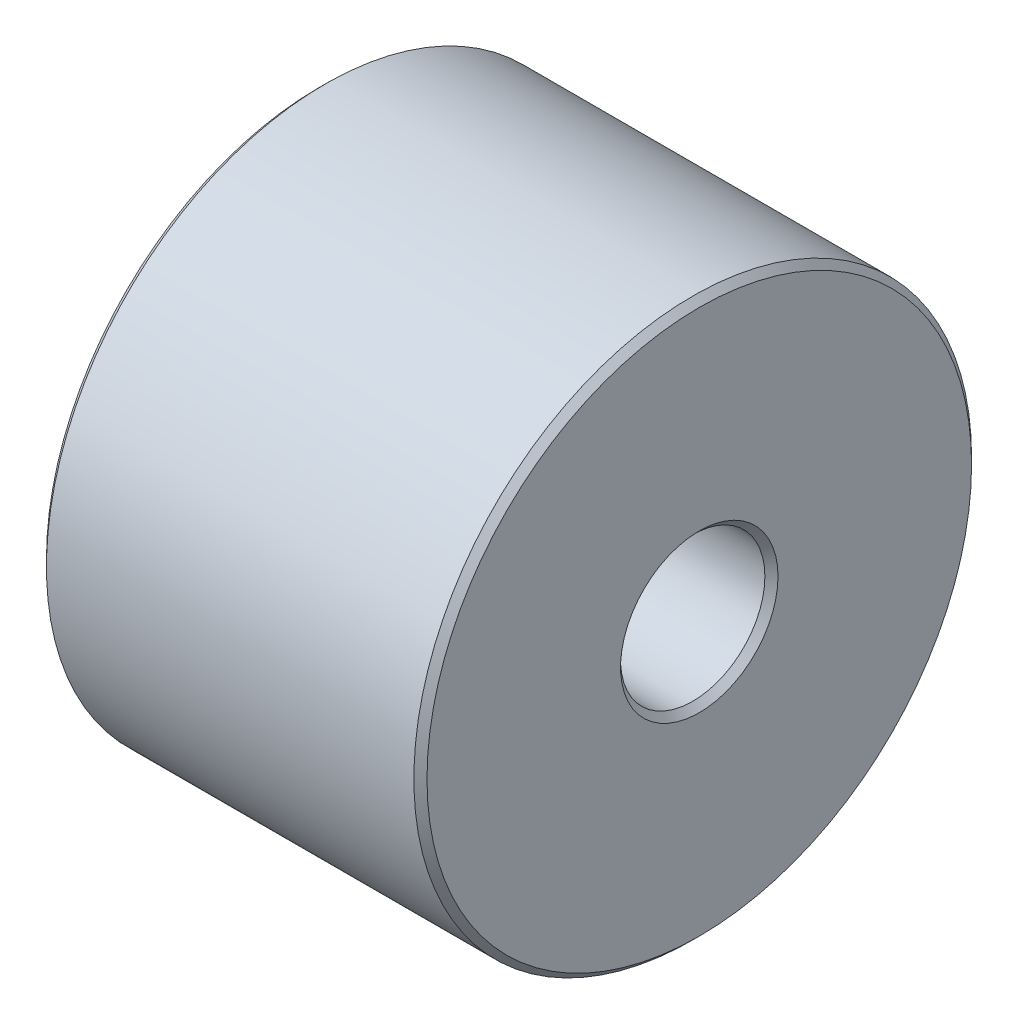
from build123d import *

# Parameters (mm, degrees)
SKETCH_1_R      = 8.5
SKETCH_1_R_2    = 2.2
EXTRUDE_1_DEPTH = 11.6
CHAMFER_1_SIZE  = 0.2


with BuildPart() as part:
    # 草图1 → 凸台-拉伸1 (new body)
    with BuildSketch(Plane(origin=(0, 0, 0), x_dir=(0, 0, -1), z_dir=(1, 0, 0))):
        Circle(SKETCH_1_R)
        Circle(SKETCH_1_R_2, mode=Mode.SUBTRACT)
    extrude(amount=EXTRUDE_1_DEPTH)

    # 倒角1
    chamfer_1_edges = [part.edges().sort_by_distance(p)[0] for p in [
        (0, 0, 8.5),
        (11.6, 0, 8.5),
        (0, 0, 2.2),
        (11.6, 0, 2.2),
    ]]
    chamfer(chamfer_1_edges, length=CHAMFER_1_SIZE)


solid = part.part
